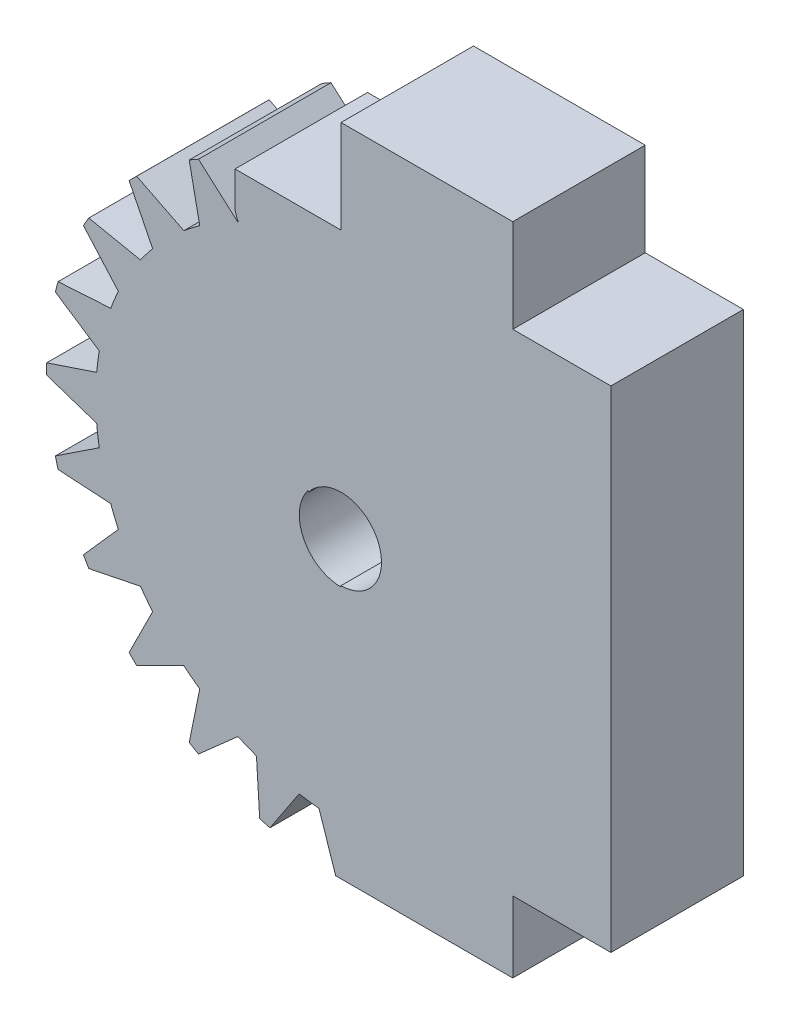
from build123d import *

# Parameters (mm, degrees)
SKETCH1_R           = 10
BOSS_EXTRUDE1_DEPTH = 5.4
BOSS_EXTRUDE2_DEPTH = 5.4
CIRPATTERN1_COUNT   = 24
SKETCH3_R           = 12.65
SKETCH3_R_2         = 12
CUT_EXTRUDE1_DEPTH  = 6
CUT_EXTRUDE2_DEPTH  = 6
SKETCH5_R           = 1.7
CUT_EXTRUDE3_DEPTH  = 6
BOSS_EXTRUDE3_DEPTH = 5.4


with BuildPart() as part:
    # Sketch1 → Boss-Extrude1 (new body)
    with BuildSketch(Plane.XY):
        Circle(SKETCH1_R)
    extrude(amount=BOSS_EXTRUDE1_DEPTH)

    # Sketch2 → Boss-Extrude2 (add)
    with BuildSketch(Plane.XY):
        with BuildLine():
            Line((0, 12.65), (-0.9, 9.959417654))
            ThreePointArc((-0.9, 9.959417654), (0, 10), (0.9, 9.959417654))
            Line((0.9, 9.959417654), (0, 12.65))
        make_face()
    boss_extrude2 = extrude(amount=BOSS_EXTRUDE2_DEPTH)

    # CirPattern1: Boss-Extrude2 ×24 about axis
    cirpattern1_axis = Axis((0, 0, 0), (0, 0, 1))
    for i in range(1, CIRPATTERN1_COUNT):
        add(boss_extrude2.rotate(cirpattern1_axis, i * 360 / CIRPATTERN1_COUNT))

    # Sketch3 → Cut-Extrude1 (cut)
    with BuildSketch(Plane.XY):
        Circle(SKETCH3_R)
        Circle(SKETCH3_R_2, mode=Mode.SUBTRACT)
    extrude(amount=CUT_EXTRUDE1_DEPTH, mode=Mode.SUBTRACT)

    # Sketch4 → Cut-Extrude2 (cut)
    with BuildSketch(Plane.XY):
        with BuildLine():
            Line((0, 0), (0, -12))
            ThreePointArc((0, -12), (11.769423365, 2.341083864), (-4.592201188, 11.08655439))
            Line((-4.592201188, 11.08655439), (-3.826834324, 9.238795325))
            Line((-3.826834324, 9.238795325), (0, 0))
        make_face()
    extrude(amount=CUT_EXTRUDE2_DEPTH, mode=Mode.SUBTRACT)

    # Sketch5 → Cut-Extrude3 (cut)
    with BuildSketch(Plane.XY):
        Circle(SKETCH5_R)
    extrude(amount=CUT_EXTRUDE3_DEPTH, mode=Mode.SUBTRACT)

    # Sketch6 → Boss-Extrude3 (add)
    with BuildSketch(Plane.XY):
        with BuildLine():
            Line((-4.32, 9.438795325), (-4.32, 10.9))
            Line((-4.32, 10.9), (0, 10.9))
            Line((0, 10.9), (0, 14.7))
            Line((0, 14.7), (7, 14.7))
            Line((7, 14.7), (7, 10.9))
            Line((7, 10.9), (11, 10.9))
            Line((11, 10.9), (11, -9.1))
            Line((11, -9.1), (7, -9.1))
            Line((7, -9.1), (7, -12))
            Line((7, -12), (0, -12))
            Line((0, -12), (0, -1.65))
            ThreePointArc((0, -1.65), (1.472580529, 0.744316187), (-1.328564272, 0.978476865))
            Line((-1.328564272, 0.978476865), (-4.32, 9.438795325))
        make_face()
    extrude(amount=BOSS_EXTRUDE3_DEPTH)


solid = part.part
